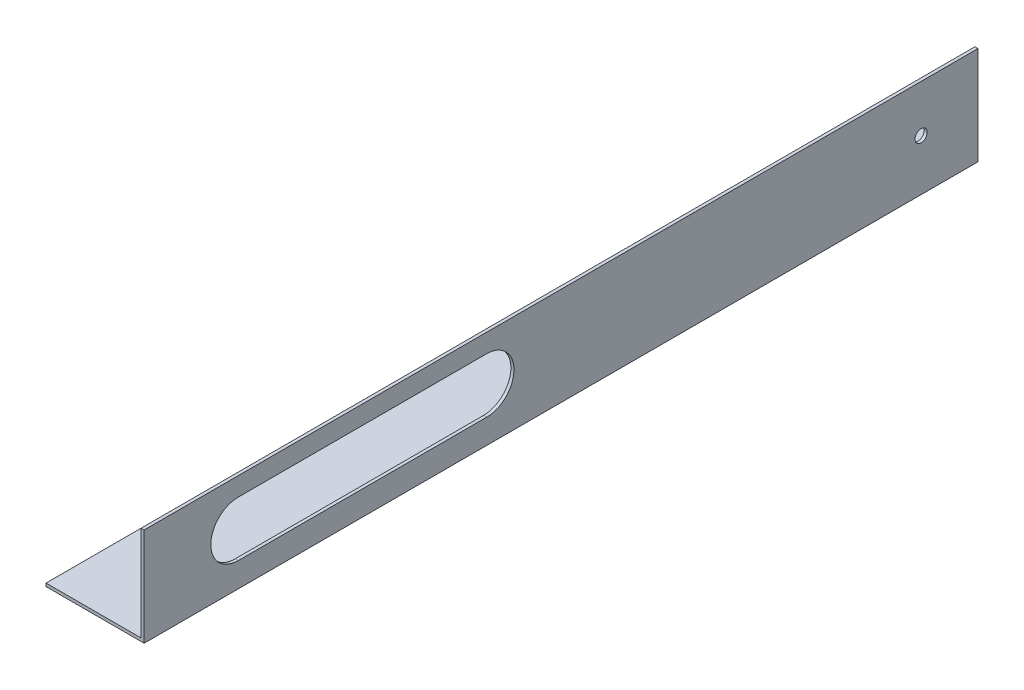
from build123d import *

# Parameters (mm, degrees)
BOSS_EXTRUDE2_DEPTH = 431.8
SKETCH8_R           = 3.175
CUT_EXTRUDE6_DEPTH  = 2.54


with BuildPart() as part:
    # Sketch3 → Boss-Extrude2 (new body)
    with BuildSketch(Plane.XY):
        Polygon((0, 0), (0, 1.5875), (49.2125, 1.5875), (49.2125, 50.8), (50.8, 50.8), (50.8, 0), align=None)
    extrude(amount=BOSS_EXTRUDE2_DEPTH)

    # Sketch8 → Cut-Extrude6 (cut)
    with BuildSketch(Plane(origin=(50.8, 0, 0), x_dir=(0, 0, -1), z_dir=(1, 0, 0))):
        with Locations((-29.464, 26.416)):
            Circle(SKETCH8_R)
        with BuildLine():
            Line((-254.508, 12.7), (-383.032, 12.7))
            ThreePointArc((-383.032, 12.7), (-397.256, 26.924), (-383.032, 41.148))
            Line((-383.032, 41.148), (-254.508, 41.148))
            ThreePointArc((-254.508, 41.148), (-240.284, 26.924), (-254.508, 12.7))
        make_face()
    extrude(amount=-CUT_EXTRUDE6_DEPTH, mode=Mode.SUBTRACT)


solid = part.part
